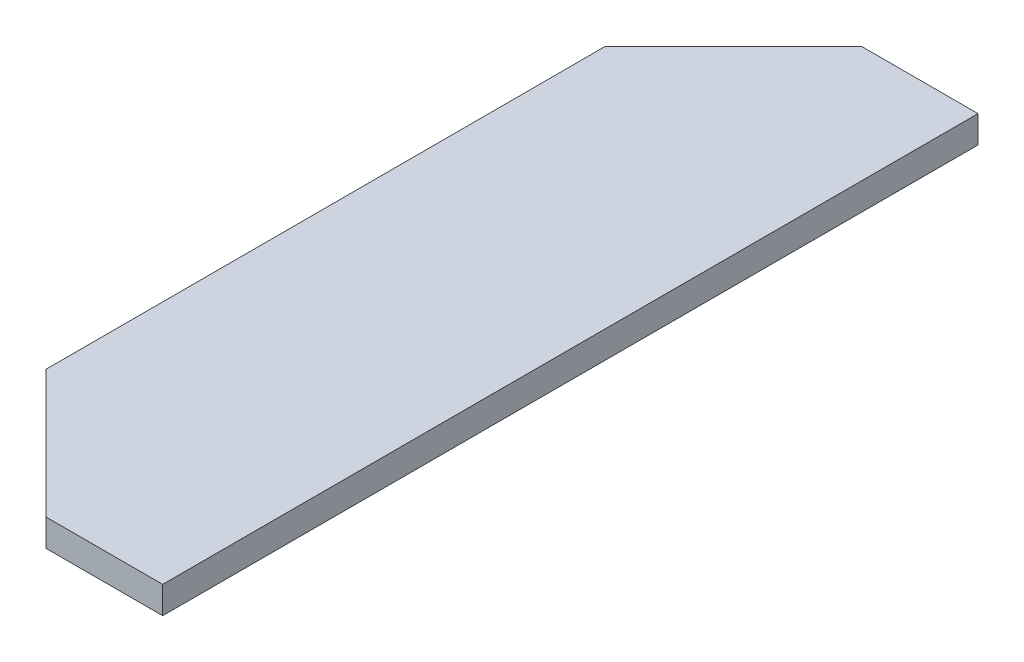
from build123d import *

# Parameters (mm, degrees)
BOSS_EXTRUDE1_DEPTH = 10


with BuildPart() as part:
    # Sketch1 → Boss-Extrude1 (new body)
    with BuildSketch(Plane(origin=(0, 0, 0), x_dir=(1, 0, 0), z_dir=(0, 1, 0))):
        Polygon((45, 150), (2.071067812, 150), (-45, 102.928932188), (-45, -102.928932188), (2.071067812, -150), (45, -150), align=None)
    extrude(amount=BOSS_EXTRUDE1_DEPTH)


solid = part.part
